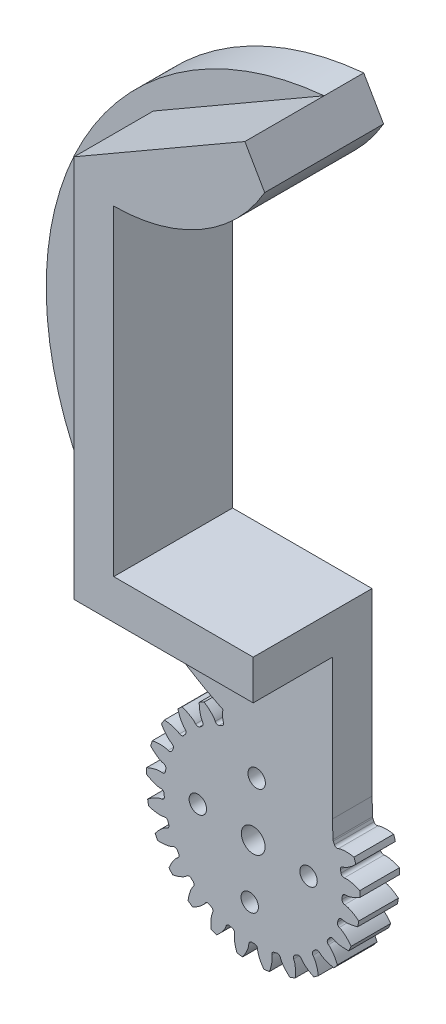
from build123d import *

# Parameters (mm, degrees)
SKETCH_1_R           = 13.5
LASHENA_DEPTH        = 5
CUT_EXTRUDEA_DEPTH   = 30
WWW_KYTOOL_CN_COUNT  = 25
EXTRUDE_2_DEPTH      = 10
EXTRUDE_2_DEPTH_BACK = 5
EXTRUDE_3_DEPTH      = 5
SKETCH_12_R          = 1.5
SKETCH_12_R_2        = 1.1
CUT_EXTRUDE_4_DEPTH  = 6.0000049
EXTRUDE_4_DEPTH      = 5
CUT_EXTRUDE_5_DEPTH  = 10
CUT_EXTRUDE_6_DEPTH  = 10
CUT_EXTRUDE_7_DEPTH  = 2


with BuildPart() as part:
    # Sketch 1 → LaShenA (new body)
    with BuildSketch(Plane.XY):
        Circle(SKETCH_1_R)
    extrude(amount=LASHENA_DEPTH)

    # SketchA → Cut-ExtrudeA (cut)
    with BuildSketch(Plane.XY.offset(5)):
        with BuildLine():
            ThreePointArc((-3.984350063, 10.520810547), (-4.141401218, 10.459985466), (-4.297524216, 10.396816129))
            ThreePointArc((-4.297524216, 10.396816129), (-4.579677411, 10.393549891), (-4.786294021, 10.585723434))
            add(Edge.make_bspline(
                [(-4.786294021, 10.585723434), (-4.804689966, 10.624676134), (-4.836949244, 10.69266095), (-4.880435936, 10.771422965), (-4.914918146, 10.825150817), (-4.943317749, 10.867301695), (-4.977370459, 10.915048119), (-5.017326263, 10.968161569), (-5.063499475, 11.026352218), (-5.116169679, 11.089334691), (-5.175613294, 11.156807226), (-5.24209304, 11.228458772), (-5.315860723, 11.303967278), (-5.397155902, 11.383000734), (-5.486205826, 11.465217384), (-5.583225013, 11.550266205), (-5.688414947, 11.637787319), (-5.801963757, 11.727412442), (-5.924045932, 11.818765334), (-6.05482202, 11.911462258), (-6.194438398, 12.005112443), (-6.343026893, 12.099318618), (-6.557737569, 12.227806993), (-6.725924413, 12.319640738), (-6.841804759, 12.379242901)],
                knots=[0.117691322, 0.117691322, 0.117691322, 0.117691322, 0.158671831, 0.189773021, 0.203463493, 0.219643142, 0.238311966, 0.259469968, 0.283117146, 0.3092535, 0.337879031, 0.368993739, 0.402597623, 0.438690683, 0.47727292, 0.518344334, 0.561904924, 0.60795469, 0.656493633, 0.707521753, 0.761039049, 0.817045522, 0.875541172, 1, 1, 1, 1], degree=3))
            ThreePointArc((-6.841804759, 12.379242901), (-5.206795461, 13.150864161), (-3.486713877, 13.707617353))
            add(Edge.make_bspline(
                [(-3.757368158, 10.993104002), (-3.770623049, 11.034092189), (-3.793645857, 11.105733983), (-3.815861732, 11.19291771), (-3.827504528, 11.255688326), (-3.83565637, 11.305855859), (-3.843517689, 11.363972189), (-3.85074982, 11.430041857), (-3.856925238, 11.504068754), (-3.861644781, 11.586036236), (-3.864500379, 11.675913552), (-3.865087588, 11.773653798), (-3.863002391, 11.879194584), (-3.85784288, 11.992457874), (-3.849209448, 12.1133501), (-3.836705428, 12.241762226), (-3.819937593, 12.377569837), (-3.798516691, 12.52063325), (-3.772057973, 12.670797641), (-3.740181719, 12.827893183), (-3.702513722, 12.991735218), (-3.658685936, 13.162124388), (-3.590124934, 13.402767955), (-3.530386525, 13.584843691), (-3.486713877, 13.707617353)],
                knots=[0.117691322, 0.117691322, 0.117691322, 0.117691322, 0.158671831, 0.189773021, 0.203463493, 0.219643142, 0.238311966, 0.259469968, 0.283117146, 0.3092535, 0.337879031, 0.368993739, 0.402597623, 0.438690683, 0.47727292, 0.518344334, 0.561904924, 0.60795469, 0.656493633, 0.707521753, 0.761039049, 0.817045522, 0.875541172, 1, 1, 1, 1], degree=3))
            ThreePointArc((-3.757368158, 10.993104002), (-3.776433342, 10.711576716), (-3.984350063, 10.520810547))
        make_face()
    cut_extrudea = extrude(amount=-CUT_EXTRUDEA_DEPTH, mode=Mode.SUBTRACT)

    # www.KYTool.cn: Cut-ExtrudeA ×25 about axis
    www_kytool_cn_axis = Axis((0, 0, -88.99), (0, 0, 1))
    for i in range(1, WWW_KYTOOL_CN_COUNT):
        add(cut_extrudea.rotate(www_kytool_cn_axis, i * 360 / WWW_KYTOOL_CN_COUNT), mode=Mode.SUBTRACT)

    # Sketch 4 → Extrude 2 (add, two sides)
    with BuildSketch(Plane(origin=(-1.008617318, -38.329057813, 5), x_dir=(1, 0, 0), z_dir=(0, 0, 1))) as extrude_2_sk:
        with BuildLine():
            Line((11.008617318, 38.329057813), (11.008617318, 68.329057813))
            Line((11.008617318, 68.329057813), (-6.591382682, 68.329057813))
            Line((-6.591382682, 68.329057813), (-6.591382682, 108.829057813))
            ThreePointArc((-6.591382682, 108.829057813), (4.408617318, 111.77649893), (12.461176202, 119.829057813))
            Line((12.461176202, 119.829057813), (9.961176202, 124.159184832))
            Line((9.961176202, 124.159184832), (-11.591382682, 111.715809159))
            Line((-11.591382682, 111.715809159), (-11.591382682, 63.329057813))
            Line((-11.591382682, 63.329057813), (6.008617318, 63.329057813))
            Line((6.008617318, 63.329057813), (6.008617318, 46.989311851))
            ThreePointArc((6.008617318, 46.989311851), (9.668871356, 43.329057813), (11.008617318, 38.329057813))
        make_face()
    extrude(amount=EXTRUDE_2_DEPTH)
    extrude(extrude_2_sk.sketch, amount=-EXTRUDE_2_DEPTH_BACK)

    # Sketch 8 → Extrude 3 (add)
    with BuildSketch(Plane(origin=(-1.008617318, -38.329057813, 5), x_dir=(1, 0, 0), z_dir=(0, 0, 1))):
        with BuildLine():
            Line((-11.591382682, 111.715809159), (9.961176202, 124.159184832))
            ThreePointArc((9.961176202, 124.159184832), (-25.062056366, 87.696978372), (6.008617318, 47.812989652))
            Line((6.008617318, 47.812989652), (6.008617318, 63.329057813))
            Line((6.008617318, 63.329057813), (-11.591382682, 63.329057813))
            Line((-11.591382682, 63.329057813), (-11.591382682, 111.715809159))
        make_face()
    extrude(amount=-EXTRUDE_3_DEPTH)

    # Sketch 12 → Cut-Extrude 4 (cut, through all)
    with BuildSketch(Plane(origin=(-1.008617318, -38.329057813, 5), x_dir=(1, 0, 0), z_dir=(0, 0, 1))):
        with Locations((1.008617318, 38.329057813)):
            Circle(SKETCH_12_R)
        with Locations((-5.977569781, 38.76859145)):
            Circle(SKETCH_12_R_2)
        with Locations((1.448150955, 45.315244912)):
            Circle(SKETCH_12_R_2)
        with Locations((7.994804417, 37.889524176)):
            Circle(SKETCH_12_R_2)
        with Locations((0.569083682, 31.342870714)):
            Circle(SKETCH_12_R_2)
    extrude(amount=-CUT_EXTRUDE_4_DEPTH, mode=Mode.SUBTRACT)

    # Sketch 13 → Extrude 4 (add)
    with BuildSketch(Plane.XY.offset(5)):
        with BuildLine():
            ThreePointArc((-1.242755191, 11.181147505), (-1.171656629, 11.196035655), (-1.104690091, 11.224180731))
            ThreePointArc((-1.104690091, 11.224180731), (-1.570284163, 11.402857707), (-2.033532347, 11.587531535))
            add(Edge.make_bspline(
                [(-2.033532347, 11.587531535), (-2.032082424, 11.581540065), (-2.020815424, 11.533792188), (-2.011492286, 11.485760201), (-2.003361426, 11.443456386)],
                knots=[0.953131762, 0.953131762, 0.953131762, 0.953131762, 0.959019491, 1, 1, 1, 1], degree=3))
            ThreePointArc((-2.003361426, 11.443456386), (-1.851027674, 11.205936868), (-1.57692656, 11.138931844))
            ThreePointArc((-1.57692656, 11.138931844), (-1.409998878, 11.16129039), (-1.242755191, 11.181147505))
        make_face()
    extrude(amount=-EXTRUDE_4_DEPTH)

    # Sketch 14 → Cut-Extrude 5 (cut)
    with BuildSketch(Plane.XY.offset(5)):
        with BuildLine():
            Line((10, 7.312754527), (10.068009146, 5.097132041))
            ThreePointArc((10.068009146, 5.097132041), (10.117688156, 5.296956094), (10.264301038, 5.441532437))
            add(Edge.make_bspline(
                [(11.586916571, 6.927724329), (11.534069284, 6.834672524), (11.452818253, 6.699299558), (11.339962754, 6.526885227), (11.257644274, 6.407932871), (11.176900793, 6.29745501), (11.098111682, 6.195287008), (11.021648759, 6.101250377), (10.947875824, 6.015153064), (10.877148228, 5.936789726), (10.809812368, 5.865942126), (10.74620547, 5.802379174), (10.686654468, 5.7458582), (10.631477885, 5.696122279), (10.580978088, 5.652910298), (10.535464068, 5.61592676), (10.495179591, 5.584936522), (10.443722914, 5.547148754), (10.36784687, 5.498802366), (10.302021783, 5.462337942), (10.264301038, 5.441532437)],
                knots=[0.358992653, 0.358992653, 0.358992653, 0.358992653, 0.461197689, 0.509736632, 0.555786399, 0.599346989, 0.640418402, 0.679000639, 0.7150937, 0.748697584, 0.779812291, 0.808437822, 0.834574177, 0.858221354, 0.879379356, 0.898048181, 0.914227829, 0.927918301, 0.959019491, 1, 1, 1, 1], degree=3))
            ThreePointArc((11.586916571, 6.927724329), (11.398426994, 7.233661732), (11.201861514, 7.534474011))
            add(Edge.make_bspline(
                [(10, 7.312754527), (10.033755727, 7.323491623), (10.103822532, 7.344743423), (10.213366196, 7.374899897), (10.331009413, 7.404046768), (10.457000556, 7.431836268), (10.591342816, 7.457855968), (10.73402363, 7.481692506), (10.938080315, 7.510396763), (11.095164443, 7.526275888), (11.201861514, 7.534474011)],
                knots=[0.368766414, 0.368766414, 0.368766414, 0.368766414, 0.402597623, 0.438690683, 0.47727292, 0.518344334, 0.561904924, 0.60795469, 0.656493633, 0.758698669, 0.758698669, 0.758698669, 0.758698669], degree=3))
        make_face()
    extrude(amount=-CUT_EXTRUDE_5_DEPTH, mode=Mode.SUBTRACT)

    # Sketch 15 → Cut-Extrude 6 (cut)
    with BuildSketch(Plane.XY.offset(15)):
        with BuildLine():
            Line((5, 25), (5, 8.660254038))
            ThreePointArc((5, 8.660254038), (8.660254038, 5), (10, 0))
            Line((10, 0), (10, 25))
            Line((10, 25), (5, 25))
        make_face()
    extrude(amount=-CUT_EXTRUDE_6_DEPTH, mode=Mode.SUBTRACT)

    # Sketch 16 → Cut-Extrude 7 (cut)
    with BuildSketch(Plane(origin=(0, 0, 0), x_dir=(-1, 0, 0), z_dir=(0, 0, -1))):
        Polygon((2.75, -1.58771324), (2.75, 1.58771324), (0, 3.175426481), (-2.75, 1.58771324), (-2.75, -1.58771324), (0, -3.175426481), align=None)
    extrude(amount=-CUT_EXTRUDE_7_DEPTH, mode=Mode.SUBTRACT)


solid = part.part
